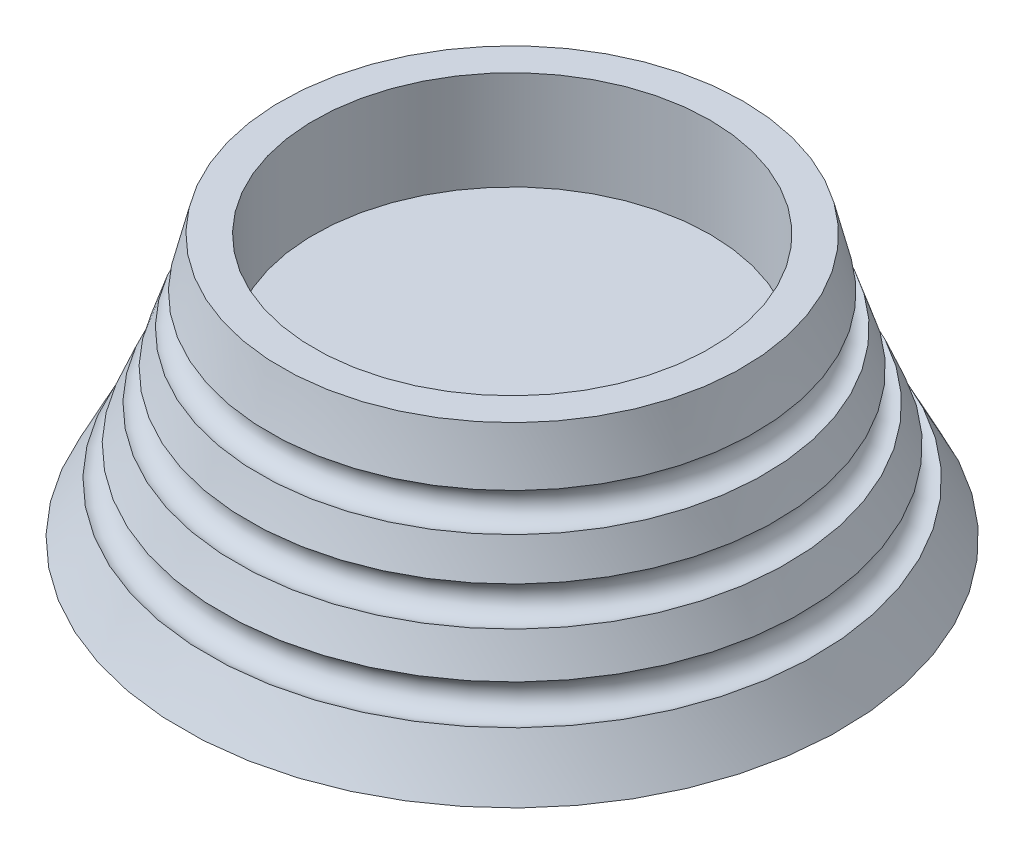
from build123d import *


with BuildPart() as part:
    # 스케치2 → 회전1 (revolve)
    with BuildSketch(Plane.XY):
        with BuildLine():
            Line((0, 0), (0, 25))
            Line((0, 25), (30, 25))
            Line((30, 25), (30, 40))
            Line((30, 40), (35, 40))
            ThreePointArc((35, 40), (35.887684521, 36.190342046), (36.874407276, 32.40512663))
            ThreePointArc((36.874407276, 32.40512663), (35.157226287, 29.297803648), (38.278751216, 27.606576642))
            ThreePointArc((38.278751216, 27.606576642), (39.124779602, 24.970916506), (40.019300618, 22.351317199))
            ThreePointArc((40.019300618, 22.351317199), (38.524440747, 19.131136981), (41.756966317, 17.663163851))
            ThreePointArc((41.756966317, 17.663163851), (42.839638308, 14.962829918), (43.974477938, 12.284001628))
            ThreePointArc((43.974477938, 12.284001628), (42.715558349, 8.964470315), (46.045465395, 7.733257201))
            ThreePointArc((46.045465395, 7.733257201), (47.966746919, 3.837999306), (50, 0))
            Line((50, 0), (0, 0))
        make_face()
    revolve(axis=Axis((0, 0, 0), (0, 1, 0)))


solid = part.part
